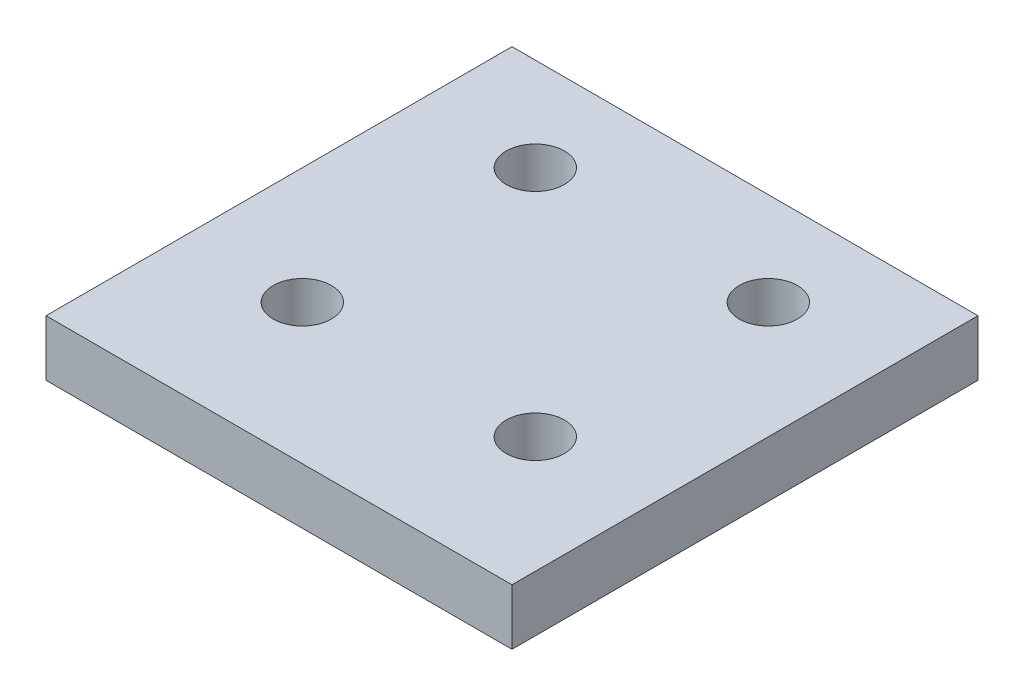
from build123d import *

# Parameters (mm, degrees)
SKETCH1_W           = 50.8
SKETCH1_H           = 50.8
SKETCH1_R           = 3.175
BOSS_EXTRUDE1_DEPTH = 6.096


with BuildPart() as part:
    # Sketch1 → Boss-Extrude1 (new body)
    with BuildSketch(Plane(origin=(0, 0, 0), x_dir=(1, 0, 0), z_dir=(0, 1, 0))):
        with Locations((-25.4, 25.4)):
            Rectangle(SKETCH1_W, SKETCH1_H)
        with Locations(Location((-38.1, 40.64, 0), (0, 0, 270))):  # turned: the seam where the file's is
            Circle(SKETCH1_R, mode=Mode.SUBTRACT)
        with Locations(Location((-12.7, 40.64, 0), (0, 0, 270))):  # turned: the seam where the file's is
            Circle(SKETCH1_R, mode=Mode.SUBTRACT)
        with Locations(Location((-12.7, 15.24, 0), (0, 0, 270))):  # turned: the seam where the file's is
            Circle(SKETCH1_R, mode=Mode.SUBTRACT)
        with Locations(Location((-38.1, 15.24, 0), (0, 0, 270))):  # turned: the seam where the file's is
            Circle(SKETCH1_R, mode=Mode.SUBTRACT)
    extrude(amount=BOSS_EXTRUDE1_DEPTH)


solid = part.part
